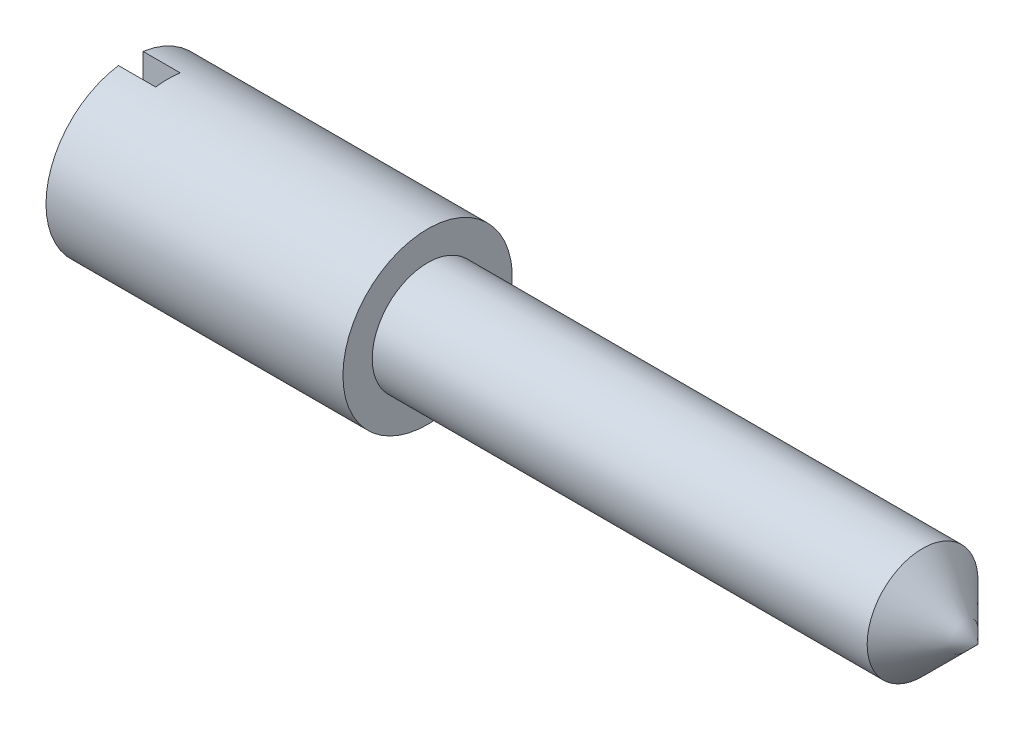
from build123d import *

# Parameters (mm, degrees)
SKETCH3_W          = 0.7874
SKETCH3_H          = 5.4356
CUT_EXTRUDE1_DEPTH = 1.1938


with BuildPart() as part:
    # Sketch2 → Revolve1 (revolve)
    with BuildSketch(Plane(origin=(0, 0, 0), x_dir=(1, 0, 0), z_dir=(0, 1, 0))):
        Polygon((0, 0), (15.875, 0), (17.653, -1.778), (-9.525, -1.778), (-9.525, 0.9398), (0, 0.9398), align=None)
    revolve(axis=Axis((-9.525, 0, 1.778), (1, 0, 0)))

    # Sketch3 → Cut-Extrude1 (cut)
    with BuildSketch(Plane.ZY.offset(9.525)):
        with Locations((1.778, 0)):
            Rectangle(SKETCH3_W, SKETCH3_H)
    extrude(amount=-CUT_EXTRUDE1_DEPTH, mode=Mode.SUBTRACT)


solid = part.part
